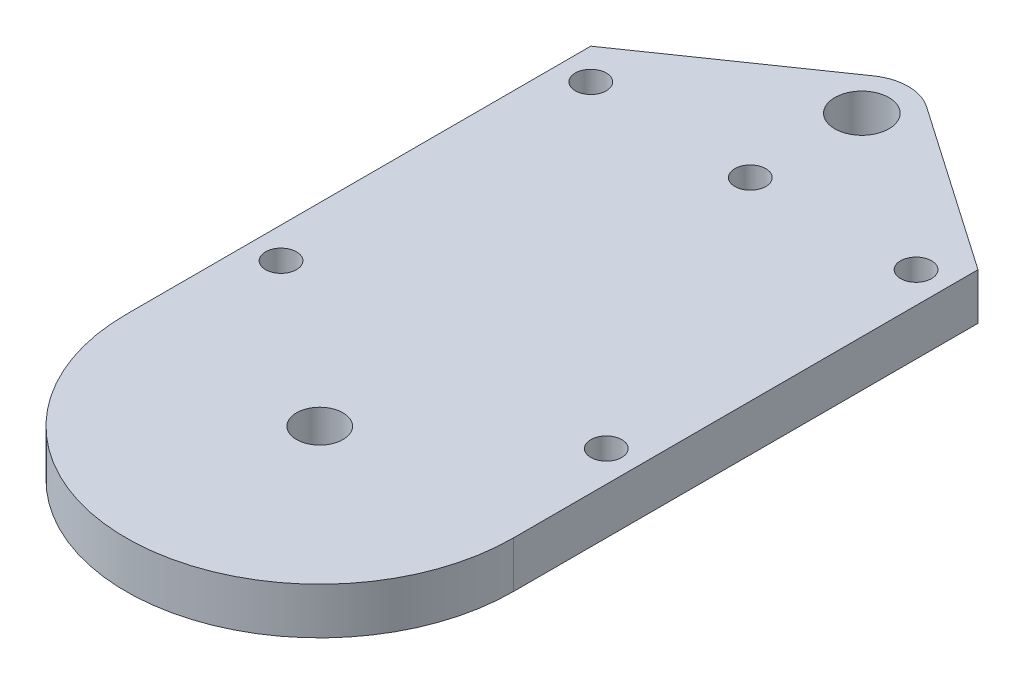
from build123d import *

# Parameters (mm, degrees)
SKETCH_1_R      = 1
SKETCH_1_R_2    = 1.5
SKETCH_1_R_3    = 1.75
EXTRUDE_1_DEPTH = 3
FILLET_1_R      = 3


with BuildPart() as part:
    # 草图1 → 凸台-拉伸1 (new body)
    with BuildSketch(Plane(origin=(0, 0, 0), x_dir=(1, 0, 0), z_dir=(0, 1, 0))):
        with BuildLine():
            Line((-12.5, 15), (-12.5, -15))
            ThreePointArc((-12.5, -15), (0, -27.5), (12.5, -15))
            Line((12.5, -15), (12.5, 15))
            Line((12.5, 15), (0, 23.647980836))
            Line((0, 23.647980836), (-12.5, 15))
        make_face()
        with Locations((-10.5, 13)):
            Circle(SKETCH_1_R, mode=Mode.SUBTRACT)
        with Locations((10.5, 13)):
            Circle(SKETCH_1_R, mode=Mode.SUBTRACT)
        with Locations((0, -15)):
            Circle(SKETCH_1_R_2, mode=Mode.SUBTRACT)
        with Locations((-10.5, -7)):
            Circle(SKETCH_1_R, mode=Mode.SUBTRACT)
        with Locations((10.5, -7)):
            Circle(SKETCH_1_R, mode=Mode.SUBTRACT)
        with Locations((0, 12.8)):
            Circle(SKETCH_1_R, mode=Mode.SUBTRACT)
        with Locations((0, 20)):
            Circle(SKETCH_1_R_3, mode=Mode.SUBTRACT)
    extrude(amount=EXTRUDE_1_DEPTH)

    # 圆角1
    fillet_1_edges = [part.edges().sort_by_distance(p)[0] for p in [
        (0, 1.5, -23.647980836),
    ]]
    fillet(fillet_1_edges, radius=FILLET_1_R)


solid = part.part
